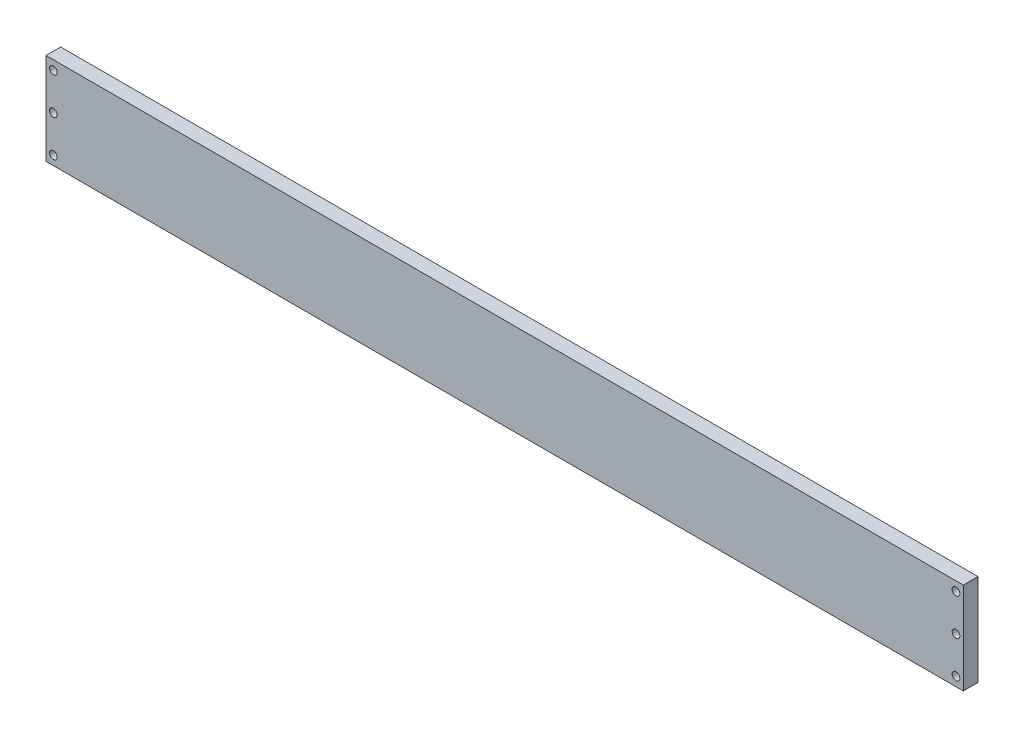
from build123d import *

# Parameters (mm, degrees)
SKETCH1_W           = 500
SKETCH1_H           = 50
SKETCH1_R           = 2.1
BOSS_EXTRUDE1_DEPTH = 8


with BuildPart() as part:
    # Sketch1 → Boss-Extrude1 (new body)
    with BuildSketch(Plane.XY):
        Rectangle(SKETCH1_W, SKETCH1_H)
        with Locations((-246, 0)):
            Circle(SKETCH1_R, mode=Mode.SUBTRACT)
        with Locations((-246, 20)):
            Circle(SKETCH1_R, mode=Mode.SUBTRACT)
        with Locations((-246, -20)):
            Circle(SKETCH1_R, mode=Mode.SUBTRACT)
        with Locations((246, 20)):
            Circle(SKETCH1_R, mode=Mode.SUBTRACT)
        with Locations((246, 0)):
            Circle(SKETCH1_R, mode=Mode.SUBTRACT)
        with Locations((246, -20)):
            Circle(SKETCH1_R, mode=Mode.SUBTRACT)
    extrude(amount=BOSS_EXTRUDE1_DEPTH)


solid = part.part
